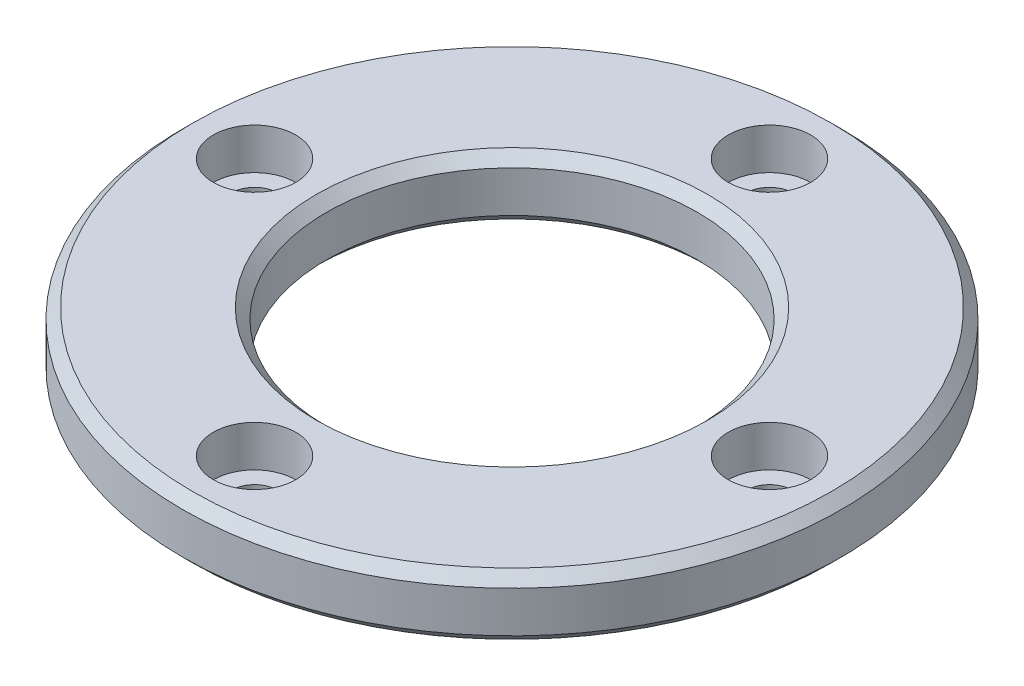
from build123d import *

# Parameters (mm, degrees)
SKETCH1_R                      = 32
SKETCH1_R_2                    = 18
BOSS_EXTRUDE1_DEPTH            = 3
CBORE_FOR_M4_SHCS1_D           = 4.5
CBORE_FOR_M4_SHCS1_CBORE_D     = 8
CBORE_FOR_M4_SHCS1_CBORE_DEPTH = 4
CHAMFER1_SIZE                  = 1
BOSS_EXTRUDE2_START            = 2
SKETCH4_R                      = 3
SKETCH4_R_2                    = 2.25
BOSS_EXTRUDE2_DEPTH            = 2
CHAMFER2_SIZE                  = 0.2
CIRPATTERN1_COUNT              = 4
CHAMFER2_OF_CIRPATTERN1_SIZE   = 0.2


with BuildPart() as part:
    # Sketch1 → Boss-Extrude1 (new, symmetric)
    with BuildSketch(Plane(origin=(0, 0, 0), x_dir=(1, 0, 0), z_dir=(0, 1, 0))):
        with Locations(Location((0, 0, 0), (0, 0, 270))):
            Circle(SKETCH1_R)
        with Locations(Location((0, 0, 0), (0, 0, 270))):
            Circle(SKETCH1_R_2, mode=Mode.SUBTRACT)
    extrude(amount=BOSS_EXTRUDE1_DEPTH, both=True)

    # CBORE for M4 SHCS1 (through all)
    with Locations(Plane(origin=(0, 3, 0), x_dir=(1, 0, 0), z_dir=(0, 1, 0))):
        with Locations((-25, 0), (0, 25), (25, 0), (0, -25)):
            CounterBoreHole(CBORE_FOR_M4_SHCS1_D / 2, CBORE_FOR_M4_SHCS1_CBORE_D / 2, CBORE_FOR_M4_SHCS1_CBORE_DEPTH)

    # Chamfer1
    chamfer1_edges = [part.edges().sort_by_distance(p)[0] for p in [
        (0, -3, -32),
        (0, 3, -32),
        (0, -3, -18),
        (0, 3, -18),
    ]]
    chamfer(chamfer1_edges, length=CHAMFER1_SIZE)

    # Sketch4 → Boss-Extrude2 (add)
    with BuildSketch(Plane.XZ.offset(3).offset(BOSS_EXTRUDE2_START)):
        with Locations(Location((-25, 0, 0), (0, 0, 90))):
            Circle(SKETCH4_R)
        with Locations(Location((-25, 0, 0), (0, 0, 90))):
            Circle(SKETCH4_R_2, mode=Mode.SUBTRACT)
    boss_extrude2 = extrude(amount=-BOSS_EXTRUDE2_DEPTH)

    # Chamfer2
    chamfer2_edges = [part.edges().sort_by_distance(p)[0] for p in [
        (-25, -5, -3),
    ]]
    chamfer(chamfer2_edges, length=CHAMFER2_SIZE)

    # CirPattern1: Boss-Extrude2 ×4 about axis
    cirpattern1_axis = Axis((0, 0, 0), (0, 1, 0))
    for i in range(1, CIRPATTERN1_COUNT):
        add(boss_extrude2.rotate(cirpattern1_axis, i * 360 / CIRPATTERN1_COUNT))

    # Chamfer2 of CirPattern1
    chamfer2_of_cirpattern1_edges = [part.edges().sort_by_distance(p)[0] for p in [
        (-3, -5, 25),
        (25, -5, 3),
        (3, -5, -25),
    ]]
    chamfer(chamfer2_of_cirpattern1_edges, length=CHAMFER2_OF_CIRPATTERN1_SIZE)


solid = part.part
